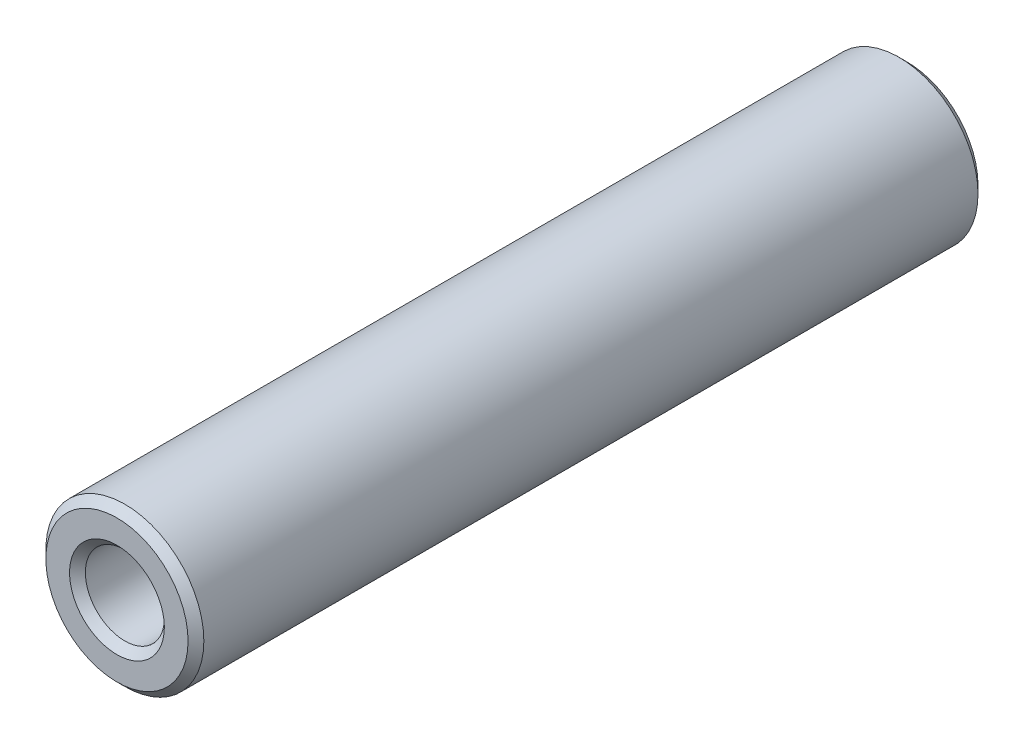
from build123d import *

# Parameters (mm, degrees)
SKETCH_1_R      = 2
SKETCH_1_R_2    = 1
EXTRUDE_1_DEPTH = 20
CHAMFER_1_SIZE  = 0.2


with BuildPart() as part:
    # Эскиз1 → Бобышка-Вытянуть1 (new body)
    with BuildSketch(Plane.XY):
        Circle(SKETCH_1_R)
        Circle(SKETCH_1_R_2, mode=Mode.SUBTRACT)
    extrude(amount=EXTRUDE_1_DEPTH)

    # Фаска1
    chamfer_1_edges = [part.edges().sort_by_distance(p)[0] for p in [
        (-2, 0, 0),
        (-2, 0, 20),
        (-1, 0, 0),
        (-1, 0, 20),
    ]]
    chamfer(chamfer_1_edges, length=CHAMFER_1_SIZE)


solid = part.part
